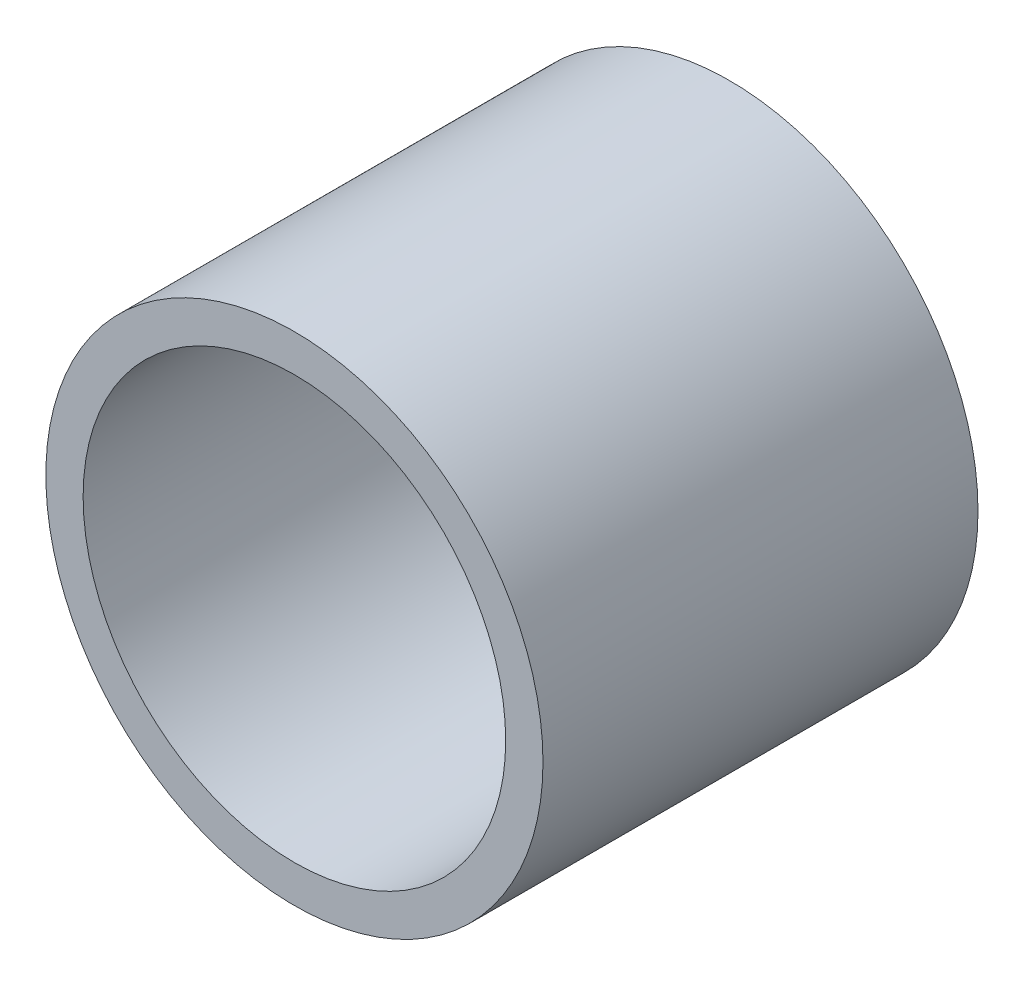
from build123d import *

# Parameters (mm, degrees)
SKETCH1_R           = 25.4
SKETCH1_R_2         = 21.59
BOSS_EXTRUDE1_DEPTH = 44.45


with BuildPart() as part:
    # Sketch1 → Boss-Extrude1 (new body)
    with BuildSketch(Plane.XY):
        Circle(SKETCH1_R)
        Circle(SKETCH1_R_2, mode=Mode.SUBTRACT)
    extrude(amount=BOSS_EXTRUDE1_DEPTH)


solid = part.part
